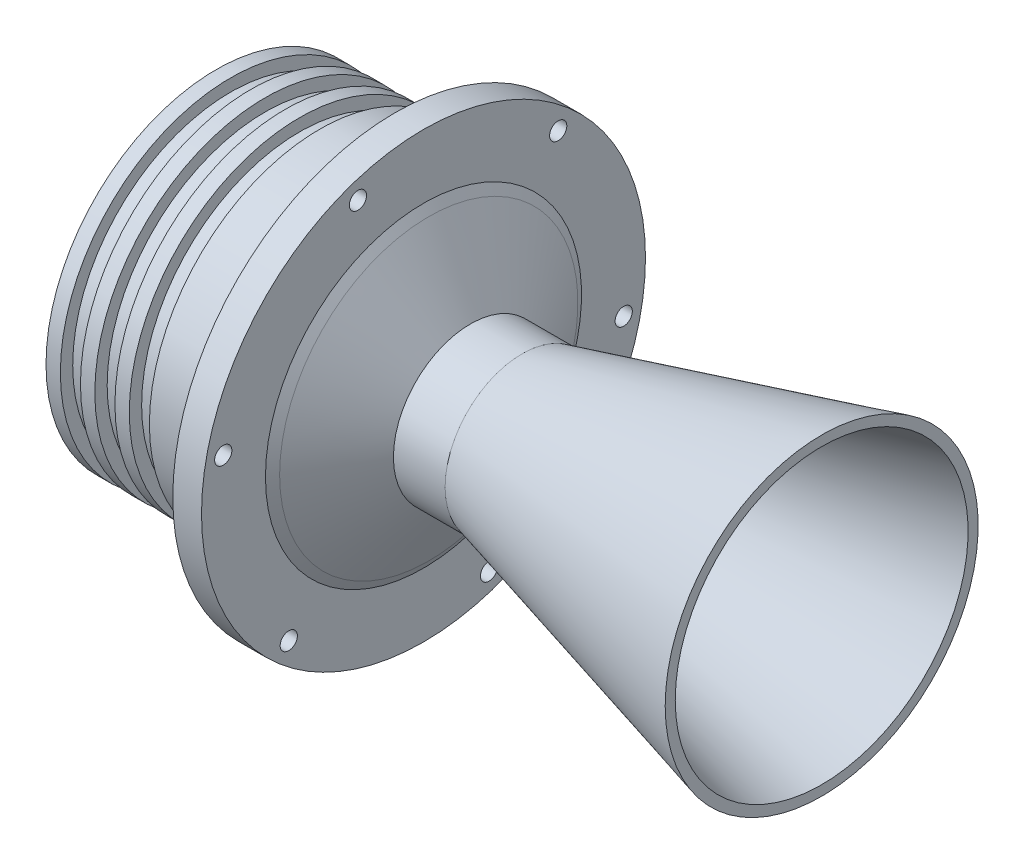
from build123d import *

# Parameters (mm, degrees)
ESQUISSE2_R                  = 3
ENL_V_MAT_EXTRU_1_DEPTH      = 10
ENL_V_MAT_EXTRU_1_DEPTH_BACK = 448


with BuildPart() as part:
    # Esquisse1 → Révolution1 (revolve)
    with BuildSketch(Plane.XY, mode=Mode.PRIVATE) as r_volution1_sk:
        with BuildLine():
            Line((-18.039330687, 17.767949192), (75.138971442, 42.735))
            Line((75.138971442, 42.735), (105.960669313, 50.993649054))
            Line((105.960669313, 50.993649054), (105.960669313, 54.493649054))
            Line((105.960669313, 54.493649054), (1.640278983, 26.81375317))
            Line((1.640278983, 26.81375317), (-16.359721017, 26.81375317))
            Line((-16.359721017, 26.81375317), (-19.950707197, 33.033523683))
            Line((-19.950707197, 33.033523683), (-30.864182635, 51.93621763))
            Line((-30.864182635, 51.93621763), (-32.699704078, 55.033523683))
            Line((-32.699704078, 55.033523683), (-32.699704078, 58.335972539))
            Line((-32.699704078, 58.335972539), (-32.699704078, 59.3))
            Line((-32.699704078, 59.3), (-32.699704078, 77.3))
            Line((-32.699704078, 77.3), (-42.699704078, 77.3))
            Line((-42.699704078, 77.3), (-42.699704078, 59.3))
            Line((-42.699704078, 59.3), (-68.850994622, 59.3))
            Line((-68.850994622, 59.3), (-68.850994622, 55))
            Line((-68.850994622, 55), (-75.850994622, 55))
            Line((-75.850994622, 55), (-75.850994622, 59.3))
            Line((-75.850994622, 59.3), (-80.850994622, 59.3))
            Line((-80.850994622, 59.3), (-80.850994622, 55))
            Line((-80.850994622, 55), (-87.850994622, 55))
            Line((-87.850994622, 55), (-87.850994622, 59.3))
            Line((-87.850994622, 59.3), (-92.850994622, 59.3))
            Line((-92.850994622, 59.3), (-92.850994622, 55))
            Line((-92.850994622, 55), (-99.850994622, 55))
            Line((-99.850994622, 55), (-99.850994622, 59.3))
            Line((-99.850994622, 59.3), (-104.850994622, 59.3))
            Line((-104.850994622, 59.3), (-99.850994622, 50))
            Line((-99.850994622, 50), (-49.762698238, 50))
            Line((-49.762698238, 50), (-39.852583688, 50))
            ThreePointArc((-39.852583688, 50), (-38.255739202, 49.559662211), (-36.97118184, 48.513850534))
            Line((-36.97118184, 48.513850534), (-19.283196137, 17.877360613))
            ThreePointArc((-19.283196137, 17.877360613), (-18.675390795, 17.662044942), (-18.039330687, 17.767949192))
        make_face()
    revolve(r_volution1_sk.sketch.rotate(Axis((-113.603789782, 0, 0), (1, 0, 0)), 90), axis=Axis((-113.603789782, 0, 0), (1, 0, 0)))  # turned: the seam where the file's is

    # Esquisse2 → Enlèv. mat.-Extru.1 (cut, two sides)
    with BuildSketch(Plane(origin=(0, 0, 0), x_dir=(0, 0, -1), z_dir=(1, 0, 0))) as enl_v_mat_extru_1_sk:
        with Locations(Location((-69.726916044, 13.905652772, 0), (0, 0, 180))):  # turned: the seam where the file's is
            Circle(ESQUISSE2_R)
        with Locations(Location((-46.906106579, -53.432454235, 0), (0, 0, 180))):  # turned: the seam where the file's is
            Circle(ESQUISSE2_R)
        with Locations(Location((22.820809465, -67.338107008, 0), (0, 0, 180))):  # turned: the seam where the file's is
            Circle(ESQUISSE2_R)
        with Locations(Location((69.726916044, -13.905652772, 0), (0, 0, 180))):  # turned: the seam where the file's is
            Circle(ESQUISSE2_R)
        with Locations(Location((46.906106579, 53.432454235, 0), (0, 0, 180))):  # turned: the seam where the file's is
            Circle(ESQUISSE2_R)
        with Locations(Location((-22.820809465, 67.338107008, 0), (0, 0, 180))):  # turned: the seam where the file's is
            Circle(ESQUISSE2_R)
    extrude(amount=ENL_V_MAT_EXTRU_1_DEPTH, mode=Mode.SUBTRACT)
    extrude(enl_v_mat_extru_1_sk.sketch, amount=-ENL_V_MAT_EXTRU_1_DEPTH_BACK, mode=Mode.SUBTRACT)


solid = part.part
